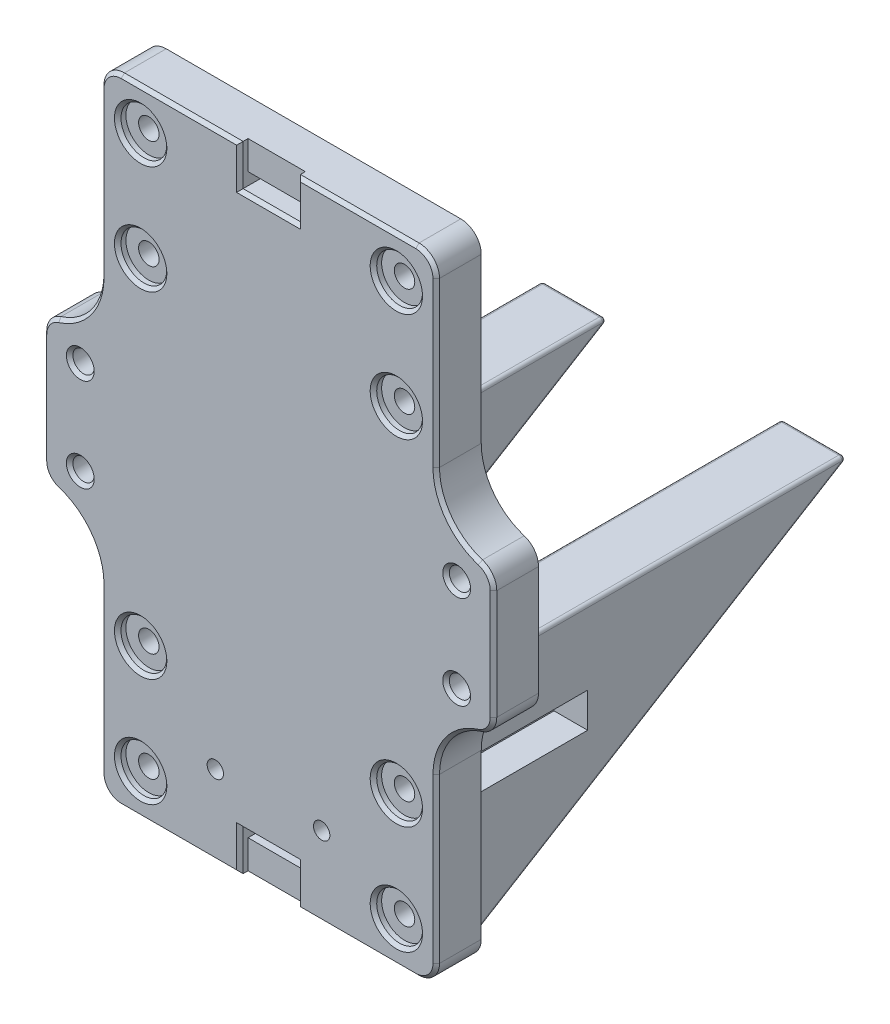
from build123d import *

# Parameters (mm, degrees)
SKETCH1_W           = 82
SKETCH1_H           = 155
SKETCH1_R           = 2.5
BOSS_EXTRUDE1_DEPTH = 11
SKETCH6_W           = 110
SKETCH6_H           = 36.8
BOSS_EXTRUDE4_DEPTH = 11
SKETCH9_W           = 14
SKETCH9_H           = 3
CUT_EXTRUDE2_DEPTH  = 12
FILLET1_R           = 5
SKETCH10_R          = 2.6
CUT_EXTRUDE3_DEPTH  = 12
FILLET3_R           = 15
SKETCH14_R          = 5.6
CUT_EXTRUDE7_DEPTH  = 2
SKETCH18_W          = 14
SKETCH18_H          = 7
CUT_EXTRUDE10_DEPTH = 2
BOSS_EXTRUDE5_DEPTH = 37
CUT_EXTRUDE8_DEPTH  = 21.5
CHAMFER2_SIZE       = 0.8
SKETCH11_R          = 2
CUT_EXTRUDE4_DEPTH  = 12.0000001
CUT_EXTRUDE5_DEPTH  = 2.6
CUT_EXTRUDE9_DEPTH  = 30
FILLET4_R           = 0.8


with BuildPart() as part:
    # Sketch1 → Boss-Extrude1 (new body)
    with BuildSketch(Plane.XY):
        Rectangle(SKETCH1_W, SKETCH1_H)
        with Locations((31.25, 41)):
            Circle(SKETCH1_R, mode=Mode.SUBTRACT)
        with Locations((31.25, -41)):
            Circle(SKETCH1_R, mode=Mode.SUBTRACT)
        with Locations((-31.25, -41)):
            Circle(SKETCH1_R, mode=Mode.SUBTRACT)
        with Locations((-31.25, 41)):
            Circle(SKETCH1_R, mode=Mode.SUBTRACT)
        with Locations((-31.25, 67.5)):
            Circle(SKETCH1_R, mode=Mode.SUBTRACT)
        with Locations((31.25, 67.5)):
            Circle(SKETCH1_R, mode=Mode.SUBTRACT)
        with Locations((31.25, -67.5)):
            Circle(SKETCH1_R, mode=Mode.SUBTRACT)
        with Locations((-31.25, -67.5)):
            Circle(SKETCH1_R, mode=Mode.SUBTRACT)
    extrude(amount=BOSS_EXTRUDE1_DEPTH)

    # Sketch6 → Boss-Extrude4 (add)
    with BuildSketch(Plane.XY.offset(11)):
        Rectangle(SKETCH6_W, SKETCH6_H)
    extrude(amount=-BOSS_EXTRUDE4_DEPTH)

    # Sketch9 → Cut-Extrude2 (cut, through all)
    with BuildSketch(Plane(origin=(0, 0, 0), x_dir=(-1, 0, 0), z_dir=(0, 0, -1))):
        with Locations((0, 69)):
            Rectangle(SKETCH9_W, SKETCH9_H)
        with Locations((0, -69)):
            Rectangle(SKETCH9_W, SKETCH9_H)
    extrude(amount=-CUT_EXTRUDE2_DEPTH, mode=Mode.SUBTRACT)

    # Fillet1
    fillet1_edges = [part.edges().sort_by_distance(p)[0] for p in [
        (-55, 18.4, 5.5),
        (55, -18.4, 5.5),
        (-55, -18.4, 5.5),
        (55, 18.4, 5.5),
        (41, -77.5, 5.5),
        (-41, -77.5, 5.5),
        (-41, 77.5, 5.5),
        (41, 77.5, 5.5),
    ]]
    fillet(fillet1_edges, radius=FILLET1_R)

    # Sketch10 → Cut-Extrude3 (cut, through all)
    with BuildSketch(Plane(origin=(0, 0, 0), x_dir=(-1, 0, 0), z_dir=(0, 0, -1))):
        with Locations((-46, 11.4)):
            Circle(SKETCH10_R)
        with Locations((-46, -11.4)):
            Circle(SKETCH10_R)
        with Locations((46, -11.4)):
            Circle(SKETCH10_R)
        with Locations((46, 11.4)):
            Circle(SKETCH10_R)
    extrude(amount=-CUT_EXTRUDE3_DEPTH, mode=Mode.SUBTRACT)

    # Fillet3
    fillet3_edges = [part.edges().sort_by_distance(p)[0] for p in [
        (41, -18.4, 5.5),
        (-41, -18.4, 5.5),
        (-41, 18.4, 5.5),
        (41, 18.4, 5.5),
    ]]
    fillet(fillet3_edges, radius=FILLET3_R)

    # Sketch14 → Cut-Extrude7 (cut)
    with BuildSketch(Plane.XY.offset(11)):
        with Locations((31.25, -41)):
            Circle(SKETCH14_R)
        with Locations((31.25, -67.5)):
            Circle(SKETCH14_R)
        with Locations((31.25, 41)):
            Circle(SKETCH14_R)
        with Locations((31.25, 67.5)):
            Circle(SKETCH14_R)
        with Locations((-31.25, 67.5)):
            Circle(SKETCH14_R)
        with Locations((-31.25, 41)):
            Circle(SKETCH14_R)
        with Locations((-31.25, -41)):
            Circle(SKETCH14_R)
        with Locations((-31.25, -67.5)):
            Circle(SKETCH14_R)
    extrude(amount=-CUT_EXTRUDE7_DEPTH, mode=Mode.SUBTRACT)

    # Sketch18 → Cut-Extrude10 (cut)
    with BuildSketch(Plane.XY.offset(11)):
        with Locations((0, 74)):
            Rectangle(SKETCH18_W, SKETCH18_H)
        with Locations((0, -74)):
            Rectangle(SKETCH18_W, SKETCH18_H)
    extrude(amount=-CUT_EXTRUDE10_DEPTH, mode=Mode.SUBTRACT)

    # Sketch16 → Boss-Extrude5 (add, symmetric)
    with BuildSketch(Plane(origin=(0, 0, 0), x_dir=(0, 0, -1), z_dir=(1, 0, 0))):
        Polygon((0, -18.5), (0, -76.5), (95, -18.5), align=None)
    extrude(amount=BOSS_EXTRUDE5_DEPTH, both=True)

    # Sketch16_2 → Cut-Extrude8 (cut, symmetric)
    with BuildSketch(Plane(origin=(0, 0, 0), x_dir=(0, 0, -1), z_dir=(1, 0, 0))):
        Polygon((0, -18.5), (0, -76.5), (95, -18.5), align=None)
    extrude(amount=CUT_EXTRUDE8_DEPTH, both=True, mode=Mode.SUBTRACT)

    # Chamfer2
    chamfer2_edges = [part.edges().sort_by_distance(p)[0] for p in [
        (41, -52.489392014, 11),
        (-21.5, -77.5, 11),
        (55, 0, 11),
        (21.5, 77.5, 11),
        (-41, 52.489392014, 11),
        (-55, 0, 11),
        (39.535533906, 76.035533906, 11),
        (54.031128874, 16.358039892, 11),
        (-39.535533906, 76.035533906, 11),
        (-54.031128874, -16.358039892, 11),
        (-39.535533906, -76.035533906, 11),
        (39.535533906, -76.035533906, 11),
        (-43.4, 11.4, 11),
        (-43.4, -11.4, 11),
        (48.6, -11.4, 11),
        (48.6, 11.4, 11),
        (54.031128874, -16.358039892, 11),
        (-41, -52.489392014, 11),
        (-54.031128874, 16.358039892, 11),
        (41, 52.489392014, 11),
        (43.906613378, -23.604664354, 11),
        (-43.906613378, -23.604664354, 11),
        (-43.906613378, 23.604664354, 11),
        (43.906613378, 23.604664354, 11),
        (25.65, -67.5, 11),
        (25.65, 41, 11),
        (25.65, 67.5, 11),
        (-36.85, 67.5, 11),
        (-36.85, 41, 11),
        (-36.85, -41, 11),
        (-36.85, -67.5, 11),
        (25.65, -41, 11),
        (21.5, -77.5, 11),
        (-21.5, 77.5, 11),
        (-7, 72.5, 11),
        (0, 67.5, 11),
        (7, 72.5, 11),
        (-7, -72.5, 11),
        (7, -72.5, 11),
        (0, -67.5, 11),
    ]]
    chamfer(chamfer2_edges, length=CHAMFER2_SIZE)

    # Sketch11 → Cut-Extrude4 (cut, through all)
    with BuildSketch(Plane(origin=(0, 0, 0), x_dir=(-1, 0, 0), z_dir=(0, 0, -1))):
        with Locations((-13, -58)):
            Circle(SKETCH11_R)
        with Locations((13, -58)):
            Circle(SKETCH11_R)
    extrude(amount=-CUT_EXTRUDE4_DEPTH, mode=Mode.SUBTRACT)

    # Sketch12 → Cut-Extrude5 (cut)
    with BuildSketch(Plane(origin=(0, 0, 0), x_dir=(-1, 0, 0), z_dir=(0, 0, -1))):
        Polygon((14.616580754, -55.2), (11.383419246, -55.2), (9.766838493, -58), (11.383419246, -60.8), (14.616580754, -60.8), (16.233161507, -58), align=None)
        Polygon((-11.383419246, -55.2), (-14.616580754, -55.2), (-16.233161507, -58), (-14.616580754, -60.8), (-11.383419246, -60.8), (-9.766838493, -58), align=None)
    extrude(amount=-CUT_EXTRUDE5_DEPTH, mode=Mode.SUBTRACT)

    # Sketch17 → Cut-Extrude9 (cut)
    with BuildSketch(Plane(origin=(0, 0, 0), x_dir=(-1, 0, 0), z_dir=(0, 0, -1))):
        Polygon((-36.157477288, -41), (-33.703738644, -36.75), (-37, -36.75), (-37, -45.25), (-33.703738644, -45.25), align=None)
        Polygon((37, -36.75), (33.703738644, -36.75), (36.157477288, -41), (33.703738644, -45.25), (37, -45.25), align=None)
        Polygon((33.703738644, -45.25), (36.157477288, -41), (33.703738644, -36.75), (28.796261356, -36.75), (26.342522712, -41), (28.796261356, -45.25), align=None)
        Polygon((33.703738644, -71.75), (36.157477288, -67.5), (33.703738644, -63.25), (28.796261356, -63.25), (26.342522712, -67.5), (28.796261356, -71.75), align=None)
        Polygon((-28.796261356, -71.75), (-26.342522712, -67.5), (-28.796261356, -63.25), (-33.703738644, -63.25), (-36.157477288, -67.5), (-33.703738644, -71.75), align=None)
        Polygon((-28.796261356, -45.25), (-26.342522712, -41), (-28.796261356, -36.75), (-33.703738644, -36.75), (-36.157477288, -41), (-33.703738644, -45.25), align=None)
    extrude(amount=CUT_EXTRUDE9_DEPTH, mode=Mode.SUBTRACT)

    # Fillet4
    fillet4_edges = [part.edges().sort_by_distance(p)[0] for p in [
        (-37, -18.5, -47.5),
        (29.25, -18.5, -95),
        (-37, -47.5, -47.5),
        (37, -18.5, -47.5),
        (37, -47.5, -47.5),
        (-29.25, -18.5, -95),
        (-21.5, -18.5, -47.5),
        (-21.5, -47.5, -47.5),
        (21.5, -18.5, -47.5),
        (21.5, -47.5, -47.5),
    ]]
    fillet(fillet4_edges, radius=FILLET4_R)


solid = part.part
